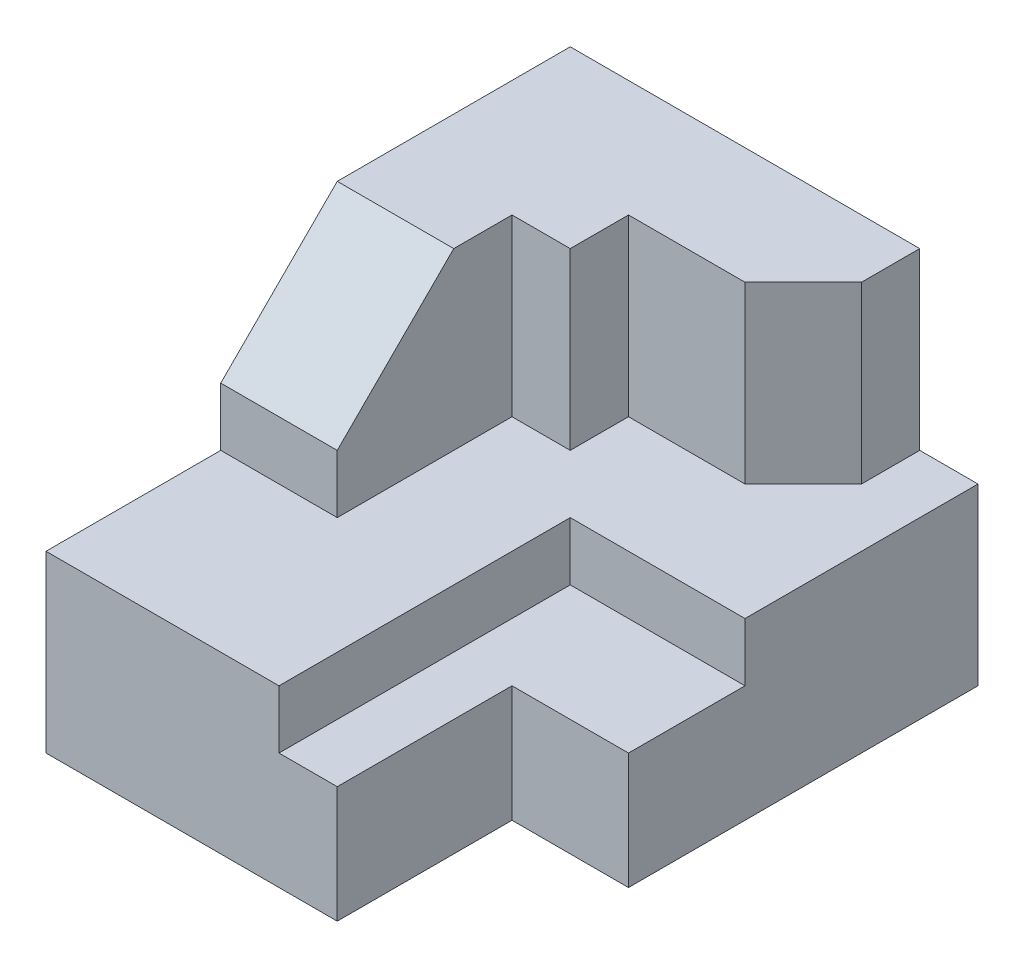
from build123d import *

# Parameters (mm, degrees)
SKETCH1_W           = 7
SKETCH1_H           = 6
BOSS_EXTRUDE1_DEPTH = 9
SKETCH2_OUTSIDE_W   = 11.576
SKETCH2_OUTSIDE_H   = 13.576
CUT_EXTRUDE1_DEPTH  = 3
SKETCH3_W           = 3
SKETCH3_H           = 5
CUT_EXTRUDE2_DEPTH  = 1
SKETCH4_W           = 2
SKETCH4_H           = 3
CUT_EXTRUDE3_DEPTH  = 2
CUT_EXTRUDE4_DEPTH  = 2


with BuildPart() as part:
    # Sketch1 → Boss-Extrude1 (new body)
    with BuildSketch(Plane.XY):
        Rectangle(SKETCH1_W, SKETCH1_H)
    extrude(amount=BOSS_EXTRUDE1_DEPTH)

    # Sketch2 outside → Cut-Extrude1 (cut)
    with BuildSketch(Plane(origin=(0, 3, 0), x_dir=(1, 0, 0), z_dir=(0, 1, 0))):
        with Locations((0, -4.5)):
            Rectangle(SKETCH2_OUTSIDE_W, SKETCH2_OUTSIDE_H)
        Polygon((2.5, 0), (2.5, -1), (1.5, -2), (-0.5, -2), (-0.5, -3), (-1.5, -3), (-1.5, -6), (-3.5, -6), (-3.5, 0), align=None, mode=Mode.SUBTRACT)
    extrude(amount=-CUT_EXTRUDE1_DEPTH, mode=Mode.SUBTRACT)

    # Sketch3 → Cut-Extrude2 (cut)
    with BuildSketch(Plane(origin=(0, 0, 0), x_dir=(1, 0, 0), z_dir=(0, 1, 0))):
        with Locations((2, -6.5)):
            Rectangle(SKETCH3_W, SKETCH3_H)
    extrude(amount=-CUT_EXTRUDE2_DEPTH, mode=Mode.SUBTRACT)

    # Sketch4 → Cut-Extrude3 (cut)
    with BuildSketch(Plane(origin=(0, -1, 0), x_dir=(1, 0, 0), z_dir=(0, 1, 0))):
        with Locations((2.5, -7.5)):
            Rectangle(SKETCH4_W, SKETCH4_H)
    extrude(amount=-CUT_EXTRUDE3_DEPTH, mode=Mode.SUBTRACT)

    # Sketch5 → Cut-Extrude4 (cut)
    with BuildSketch(Plane(origin=(-1.5, 0, 0), x_dir=(0, 0, -1), z_dir=(1, 0, 0))):
        Polygon((-4, 3), (-6, 1), (-6, 3), align=None)
    extrude(amount=-CUT_EXTRUDE4_DEPTH, mode=Mode.SUBTRACT)


solid = part.part
